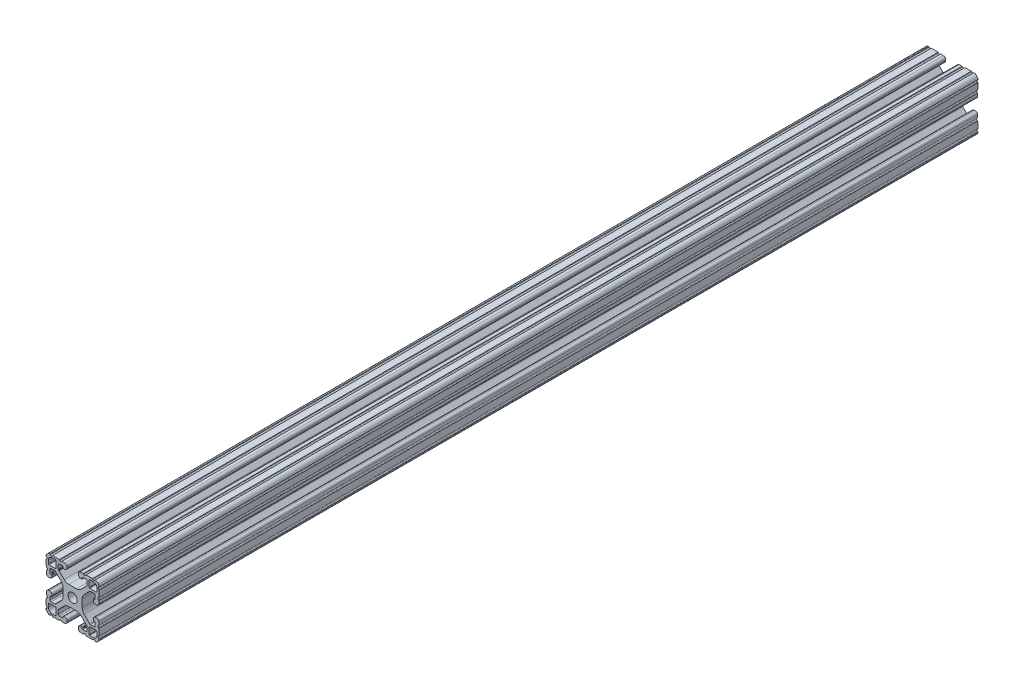
from build123d import *

# Parameters (mm, degrees)
BOSS_EXTRUDE1_DEPTH     = 457.2
CUT_EXTRUDE2_DEPTH      = 458.2
CUT_EXTRUDE2_DEPTH_BACK = 458.2
CUT_EXTRUDE1_DEPTH      = 458.2
CUT_EXTRUDE1_DEPTH_BACK = 458.2
SKETCH10_W              = 333.236610395
SKETCH10_H              = 83.20539106
CUT_EXTRUDE5_DEPTH      = 29.21


with BuildPart() as part:
    # Sketch4 → Boss-Extrude1 (new body, symmetric)
    with BuildSketch(Plane.XY):
        with BuildLine():
            Line((15.764194098, -19.048065876), (5.596097049, -18.692988103))
            ThreePointArc((5.596097049, -18.692988103), (4.509548067, -18.209225328), (4.064, -17.106455165))
            Line((4.064, -17.106455165), (4.064, -16.343990692))
            ThreePointArc((4.064, -16.343990692), (4.548729837, -15.202038759), (5.706902951, -14.757457754))
            Line((5.706902951, -14.757457754), (6.490296708, -14.784814467))
            ThreePointArc((6.490296708, -14.784814467), (6.751068464, -14.900917533), (6.858, -15.165582372))
            Line((6.858, -15.165582372), (6.858, -15.689138401))
            ThreePointArc((6.858, -15.689138401), (6.964931536, -15.95380324), (7.225703292, -16.069906306))
            Line((7.225703292, -16.069906306), (9.465548524, -16.148123425))
            ThreePointArc((9.465548524, -16.148123425), (10.044635082, -15.925832923), (10.287, -15.354856956))
            Line((10.287, -15.354856956), (10.287, -12.771043484))
            ThreePointArc((10.287, -12.771043484), (10.226579379, -12.46728851), (10.054516008, -12.209777477))
            Line((10.054516008, -12.209777477), (6.093922742, -8.249184211))
            ThreePointArc((6.093922742, -8.249184211), (4.552976719, -7.219556996), (2.735306952, -6.858))
            Line((2.735306952, -6.858), (0, -6.858))
            Line((0, -6.858), (0, -3.2639))
            ThreePointArc((0, -3.2639), (2.307925823, -2.307925823), (3.2639, 0))
            Line((3.2639, 0), (6.858, 0))
            Line((6.858, 0), (6.858, -2.735306952))
            ThreePointArc((6.858, -2.735306952), (7.219556996, -4.552976719), (8.249184211, -6.093922742))
            Line((8.249184211, -6.093922742), (12.209777477, -10.054516008))
            ThreePointArc((12.209777477, -10.054516008), (12.46728851, -10.226579379), (12.771043484, -10.287))
            Line((12.771043484, -10.287), (15.354856956, -10.287))
            ThreePointArc((15.354856956, -10.287), (15.925832923, -10.044635082), (16.148123425, -9.465548524))
            Line((16.148123425, -9.465548524), (16.069906306, -7.225703292))
            ThreePointArc((16.069906306, -7.225703292), (15.95380324, -6.964931536), (15.689138401, -6.858))
            Line((15.689138401, -6.858), (15.165582372, -6.858))
            ThreePointArc((15.165582372, -6.858), (14.900917533, -6.751068464), (14.784814467, -6.490296708))
            Line((14.784814467, -6.490296708), (14.757457754, -5.706902951))
            ThreePointArc((14.757457754, -5.706902951), (15.202038759, -4.548729837), (16.343990692, -4.064))
            Line((16.343990692, -4.064), (17.106455165, -4.064))
            ThreePointArc((17.106455165, -4.064), (18.209225328, -4.509548067), (18.692988103, -5.596097049))
            Line((18.692988103, -5.596097049), (19.048065876, -15.764194098))
            ThreePointArc((19.048065876, -15.764194098), (18.12006403, -18.12006403), (15.764194098, -19.048065876))
        make_face()
        with BuildLine():
            Line((11.8872, -12.2682), (11.8872, -16.943575443))
            ThreePointArc((11.8872, -16.943575443), (11.994131536, -17.208240282), (12.254903292, -17.324343348))
            Line((12.254903292, -17.324343348), (14.445350862, -17.400835462))
            ThreePointArc((14.445350862, -17.400835462), (16.565633801, -16.565633801), (17.400835462, -14.445350862))
            Line((17.400835462, -14.445350862), (17.324343348, -12.254903292))
            ThreePointArc((17.324343348, -12.254903292), (17.208240282, -11.994131536), (16.943575443, -11.8872))
            Line((16.943575443, -11.8872), (12.2682, -11.8872))
            ThreePointArc((12.2682, -11.8872), (11.998792316, -11.998792316), (11.8872, -12.2682))
        make_face(mode=Mode.SUBTRACT)
    extrude(amount=BOSS_EXTRUDE1_DEPTH, both=True)

    # Sketch8 → Cut-Extrude2 (cut, two sides)
    with BuildSketch(Plane.XY) as cut_extrude2_sk:
        with BuildLine():
            Line((7.649186899, -18.76468358), (9.495813101, -18.829169188))
            Line((9.495813101, -18.829169188), (9.278946369, -18.421302187))
            ThreePointArc((9.278946369, -18.421302187), (8.600423087, -17.997313783), (7.893976718, -18.372937981))
            Line((7.893976718, -18.372937981), (7.649186899, -18.76468358))
        make_face()
        with BuildLine():
            Line((14.316686899, -18.997517811), (16.163313101, -19.062003418))
            Line((16.163313101, -19.062003418), (15.946446369, -18.654136417))
            ThreePointArc((15.946446369, -18.654136417), (15.267923087, -18.230148014), (14.561476718, -18.605772211))
            Line((14.561476718, -18.605772211), (14.316686899, -18.997517811))
        make_face()
        with BuildLine():
            Line((18.605772211, -14.561476718), (18.997517811, -14.316686899))
            Line((18.997517811, -14.316686899), (19.062003418, -16.163313101))
            Line((19.062003418, -16.163313101), (18.654136417, -15.946446369))
            ThreePointArc((18.654136417, -15.946446369), (18.230148014, -15.267923087), (18.605772211, -14.561476718))
        make_face()
        with BuildLine():
            Line((18.372937981, -7.893976718), (18.76468358, -7.649186899))
            Line((18.76468358, -7.649186899), (18.829169188, -9.495813101))
            Line((18.829169188, -9.495813101), (18.421302187, -9.278946369))
            ThreePointArc((18.421302187, -9.278946369), (17.997313783, -8.600423087), (18.372937981, -7.893976718))
        make_face()
    extrude(amount=CUT_EXTRUDE2_DEPTH, mode=Mode.SUBTRACT)
    extrude(cut_extrude2_sk.sketch, amount=-CUT_EXTRUDE2_DEPTH_BACK, mode=Mode.SUBTRACT)

    # Mirror1: part across plane


with BuildPart() as part_1:
    add(part.part)
    add(part.part.mirror(Plane(origin=(0, 0, 0), x_dir=(0, 0, 1), z_dir=(1, 0, 0))))

    # Mirror2: part across plane


with BuildPart() as part_2:
    add(part_1.part)
    add(part_1.part.mirror(Plane.ZX))

    # Sketch5 → Cut-Extrude1 (cut, two sides)
    with BuildSketch(Plane.XY) as cut_extrude1_sk:
        with BuildLine():
            Line((-10.133783723, 12.50797511), (-10.133783723, 11.99997511))
            ThreePointArc((-10.133783723, 11.99997511), (-10.084187138, 11.880238362), (-9.964450389, 11.830641777))
            Line((-9.964450389, 11.830641777), (-9.650582015, 11.830641777))
            Line((-9.650582015, 11.830641777), (-9.650582015, 12.50797511))
            Line((-9.650582015, 12.50797511), (-10.133783723, 12.50797511))
        make_face()
    extrude(amount=CUT_EXTRUDE1_DEPTH, mode=Mode.SUBTRACT)
    extrude(cut_extrude1_sk.sketch, amount=-CUT_EXTRUDE1_DEPTH_BACK, mode=Mode.SUBTRACT)

    # Sketch10 → Cut-Extrude5 (cut, symmetric)
    with BuildSketch(Plane(origin=(0, 0, 0), x_dir=(0, 0, -1), z_dir=(1, 0, 0))):
        with Locations((-337.868305198, 4.815144227)):
            Rectangle(SKETCH10_W, SKETCH10_H)
    extrude(amount=CUT_EXTRUDE5_DEPTH, both=True, mode=Mode.SUBTRACT)


solid = part_2.part
